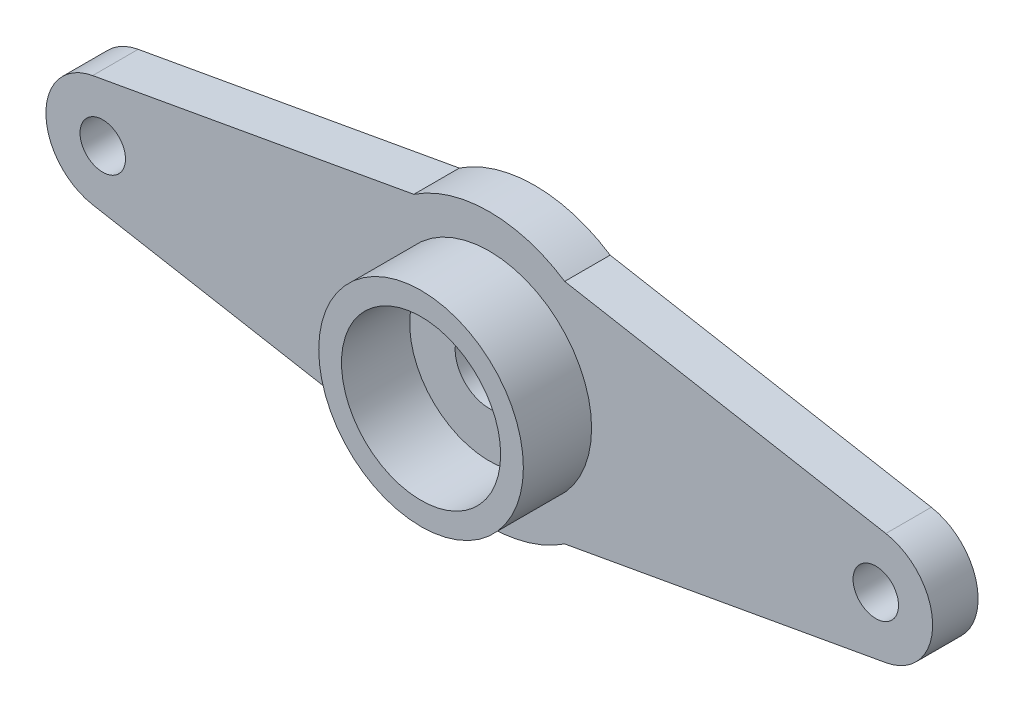
from build123d import *

# Parameters (mm, degrees)
SKETCH1_R           = 1.5
BOSS_EXTRUDE1_DEPTH = 2
SKETCH2_R           = 4.5
SKETCH2_R_2         = 3.5
BOSS_EXTRUDE2_DEPTH = 3
SKETCH3_R           = 1
CUT_EXTRUDE1_DEPTH  = 3


with BuildPart() as part:
    # Sketch1 → Boss-Extrude1 (new body)
    with BuildSketch(Plane.XY):
        with BuildLine():
            Line((-17.442345164, 2.460554969), (-3.31662479, 5))
            ThreePointArc((-3.31662479, 5), (0, 6), (3.31662479, 5))
            Line((3.31662479, 5), (17.442345164, 2.460554969))
            ThreePointArc((17.442345164, 2.460554969), (19.5, 0), (17.442345164, -2.460554969))
            Line((17.442345164, -2.460554969), (3.31662479, -5))
            ThreePointArc((3.31662479, -5), (0, -6), (-3.31662479, -5))
            Line((-3.31662479, -5), (-17.442345164, -2.460554969))
            ThreePointArc((-17.442345164, -2.460554969), (-19.5, 0), (-17.442345164, 2.460554969))
        make_face()
        Circle(SKETCH1_R, mode=Mode.SUBTRACT)
    extrude(amount=BOSS_EXTRUDE1_DEPTH)

    # Sketch2 → Boss-Extrude2 (add)
    with BuildSketch(Plane.XY.offset(2)):
        Circle(SKETCH2_R)
        Circle(SKETCH2_R_2, mode=Mode.SUBTRACT)
    extrude(amount=BOSS_EXTRUDE2_DEPTH)

    # Sketch3 → Cut-Extrude1 (cut, through all)
    with BuildSketch(Plane.XY.offset(2)):
        with Locations((-17, 0)):
            Circle(SKETCH3_R)
        with Locations((17, 0)):
            Circle(SKETCH3_R)
    extrude(amount=-CUT_EXTRUDE1_DEPTH, mode=Mode.SUBTRACT)


solid = part.part
